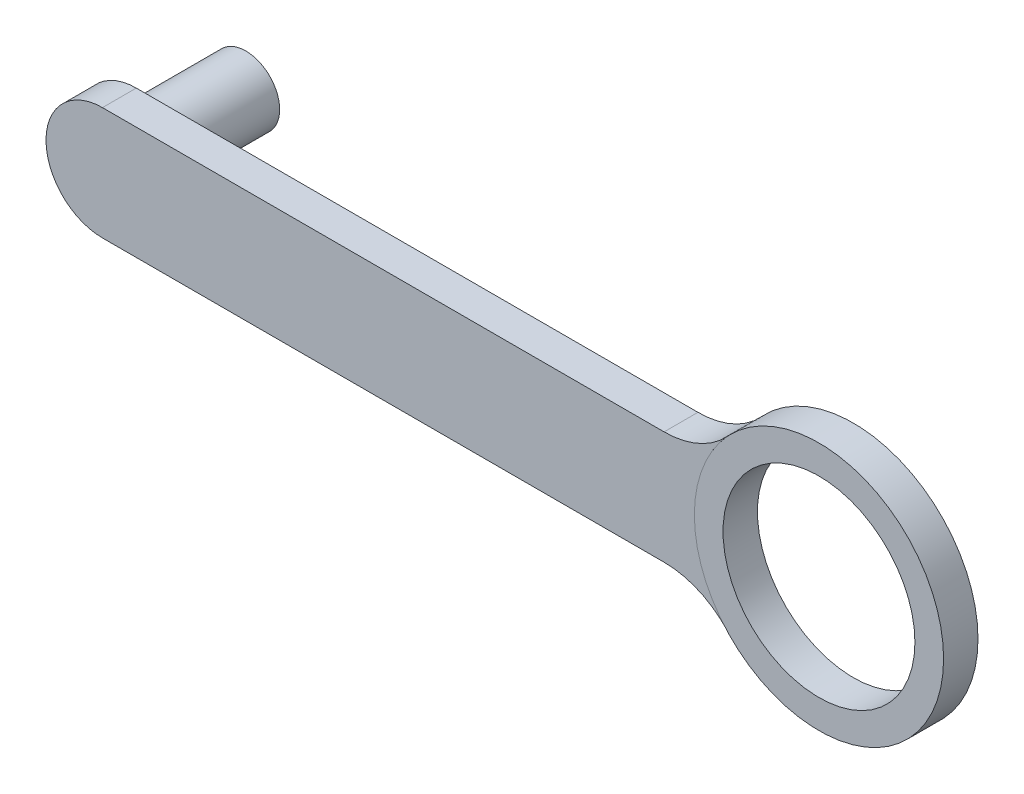
from build123d import *

# Parameters (mm, degrees)
SKETCH1_R           = 3
BOSS_EXTRUDE1_DEPTH = 1.5
SKETCH2_R           = 3
BOSS_EXTRUDE2_DEPTH = 12.7
SKETCH3_R           = 11.04
BOSS_EXTRUDE3_DEPTH = 1.524
FILLET1_R           = 7.62
SKETCH4_R           = 8.5
CUT_EXTRUDE1_DEPTH  = 13.724


with BuildPart() as part:
    # Sketch1 → Boss-Extrude1 (new body, symmetric)
    with BuildSketch(Plane.XY):
        with BuildLine():
            Line((-31.75, 5), (31.75, 5))
            ThreePointArc((31.75, 5), (36.75, 0), (31.75, -5))
            Line((31.75, -5), (-31.75, -5))
            ThreePointArc((-31.75, -5), (-36.75, 0), (-31.75, 5))
        make_face()
        with Locations((-31.75, 0)):
            Circle(SKETCH1_R, mode=Mode.SUBTRACT)
        with Locations((31.75, 0)):
            Circle(SKETCH1_R, mode=Mode.SUBTRACT)
    extrude(amount=BOSS_EXTRUDE1_DEPTH, both=True)

    # Sketch2 → Boss-Extrude2 (add)
    with BuildSketch(Plane.XY.offset(1.5)):
        with Locations((-31.75, 0)):
            Circle(SKETCH2_R)
    extrude(amount=-BOSS_EXTRUDE2_DEPTH)

    # Sketch3 → Boss-Extrude3 (add, symmetric)
    with BuildSketch(Plane.XY):
        with Locations((31.75, 0)):
            Circle(SKETCH3_R)
    extrude(amount=BOSS_EXTRUDE3_DEPTH, both=True)

    # Fillet1
    fillet1_edges = [part.edges().sort_by_distance(p)[0] for p in [
        (21.907154883, 5, 0),
        (21.907154883, -5, 0),
    ]]
    fillet(fillet1_edges, radius=FILLET1_R)

    # Sketch4 → Cut-Extrude1 (cut, through all)
    with BuildSketch(Plane.XY.offset(1.524)):
        with Locations((31.75, 0)):
            Circle(SKETCH4_R)
    extrude(amount=-CUT_EXTRUDE1_DEPTH, mode=Mode.SUBTRACT)


solid = part.part
